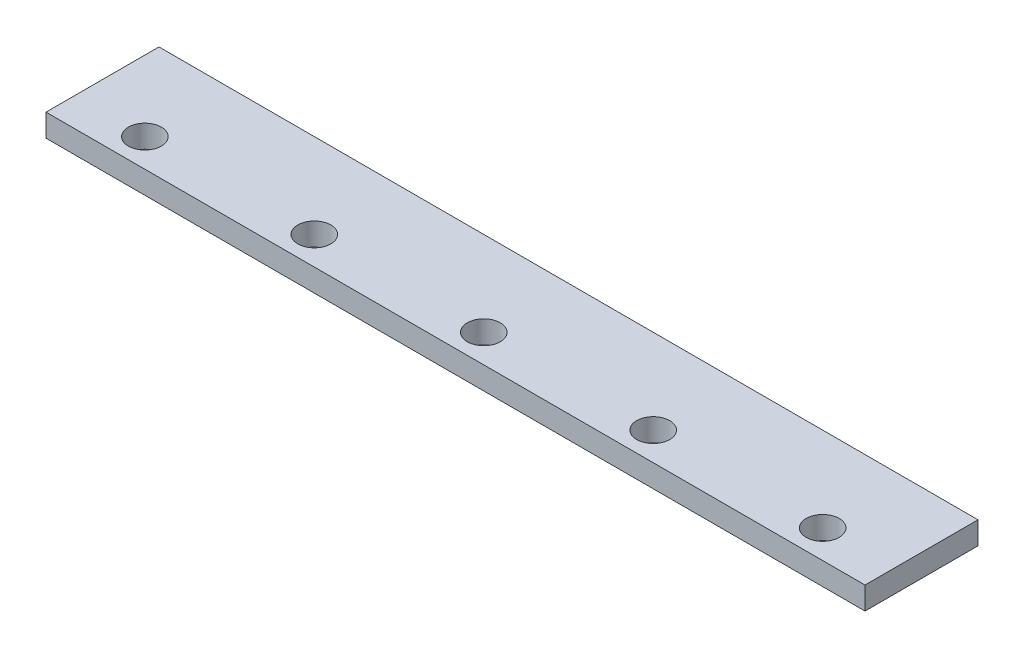
from build123d import *

# Parameters (mm, degrees)
SKETCH2_W           = 580
SKETCH2_H           = 80
BOSS_EXTRUDE1_DEPTH = 16
SKETCH3_R           = 11.669157558
CUT_EXTRUDE1_DEPTH  = 16


with BuildPart() as part:
    # Sketch2 → Boss-Extrude1 (new body)
    with BuildSketch(Plane(origin=(0, 0, 0), x_dir=(1, 0, 0), z_dir=(0, 1, 0))):
        with Locations((290, 40)):
            Rectangle(SKETCH2_W, SKETCH2_H)
    extrude(amount=BOSS_EXTRUDE1_DEPTH)

    # Sketch3 → Cut-Extrude1 (cut)
    with BuildSketch(Plane(origin=(0, 16, 0), x_dir=(1, 0, 0), z_dir=(0, 1, 0))):
        with Locations(Location((50, 20, 0), (0, 0, 270))):  # turned: the seam where the file's is
            Circle(SKETCH3_R)
        with Locations(Location((170, 20, 0), (0, 0, 270))):  # turned: the seam where the file's is
            Circle(SKETCH3_R)
        with Locations(Location((290, 20, 0), (0, 0, 270))):  # turned: the seam where the file's is
            Circle(SKETCH3_R)
        with Locations(Location((410, 20, 0), (0, 0, 270))):  # turned: the seam where the file's is
            Circle(SKETCH3_R)
        with Locations(Location((530, 20, 0), (0, 0, 270))):  # turned: the seam where the file's is
            Circle(SKETCH3_R)
    extrude(amount=-CUT_EXTRUDE1_DEPTH, mode=Mode.SUBTRACT)


solid = part.part
